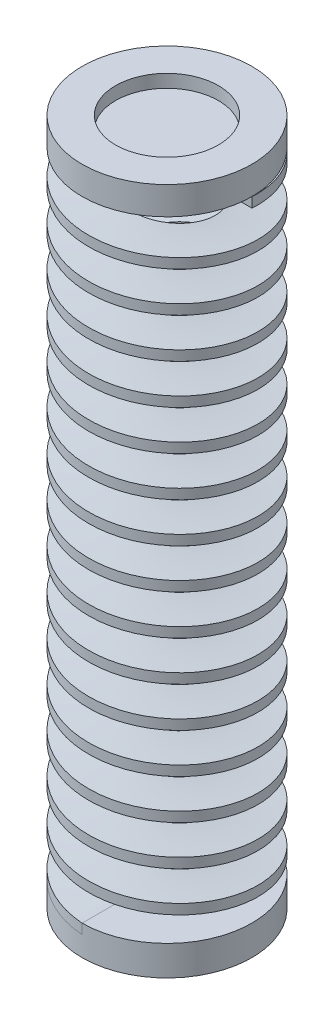
from build123d import *

# Parameters (mm, degrees)
SWEEP1_PITCH        = 4
SWEEP1_HEIGHT       = 63
SWEEP1_RADIUS       = 7.5
SKETCH4_W           = 4.25
SKETCH4_H           = 1
SKETCH5_R           = 8.5
BOSS_EXTRUDE1_DEPTH = 2
SKETCH6_R           = 8.5
SKETCH6_R_2         = 5.15
BOSS_EXTRUDE2_DEPTH = 1
SKETCH9_R           = 8.5
BOSS_EXTRUDE5_DEPTH = 1.5
SKETCH10_R          = 8.5
SKETCH10_R_2        = 5.15
BOSS_EXTRUDE6_DEPTH = 1.3


with BuildPart() as part:
    # Sweep1: sweep along a helix
    with BuildLine() as sweep1_path:
        Helix(SWEEP1_PITCH, SWEEP1_HEIGHT, SWEEP1_RADIUS, center=(0, 0, 0), direction=(0, 1, 0), lefthand=True)
    # Sketch4 → Sweep1 (sweep)
    with BuildSketch(Plane.XY):
        with Locations((-6.375, 0.500000002)):
            Rectangle(SKETCH4_W, SKETCH4_H)
    sweep(path=sweep1_path.line, is_frenet=True)


with BuildPart() as boss_extrude1_tool:
    # Sketch5 → Boss-Extrude1 (new body)
    with BuildSketch(Plane(origin=(0, 0, 0), x_dir=(1, 0, 0), z_dir=(0, 1, 0))):
        with Locations(Location((0, 0, 0), (0, 0, 270))):
            Circle(SKETCH5_R)
    extrude(amount=-BOSS_EXTRUDE1_DEPTH)


with BuildPart() as part_1:
    add(part.part)


with BuildPart() as part_2:
    # Boss-Extrude1: joined with boss_extrude1_tool
    add(part_1.part.fuse(boss_extrude1_tool.part, tol=0.00001))

    # Sketch6 → Boss-Extrude2 (add)
    with BuildSketch(Plane.XZ.offset(2)):
        with Locations(Location((0, 0, 0), (0, 0, 90))):
            Circle(SKETCH6_R)
        with Locations(Location((0, 0, 0), (0, 0, 270))):
            Circle(SKETCH6_R_2, mode=Mode.SUBTRACT)
    extrude(amount=BOSS_EXTRUDE2_DEPTH)


with BuildPart() as body_2:
    # Sketch9 → Boss-Extrude5 (new body)
    with BuildSketch(Plane(origin=(0, 63.000000002, 0), x_dir=(1, 0, 0), z_dir=(0, 1, 0))):
        with Locations(Location((0, 0, 0), (0, 0, 270))):
            Circle(SKETCH9_R)
    extrude(amount=BOSS_EXTRUDE5_DEPTH)

    # Sketch10 → Boss-Extrude6 (add)
    with BuildSketch(Plane(origin=(0, 64.500000002, 0), x_dir=(1, 0, 0), z_dir=(0, 1, 0))):
        with Locations(Location((0, 0, 0), (0, 0, 270))):
            Circle(SKETCH10_R)
        with Locations(Location((0, 0, 0), (0, 0, 270))):
            Circle(SKETCH10_R_2, mode=Mode.SUBTRACT)
    extrude(amount=BOSS_EXTRUDE6_DEPTH)


solid = Compound([part_2.part, body_2.part])
